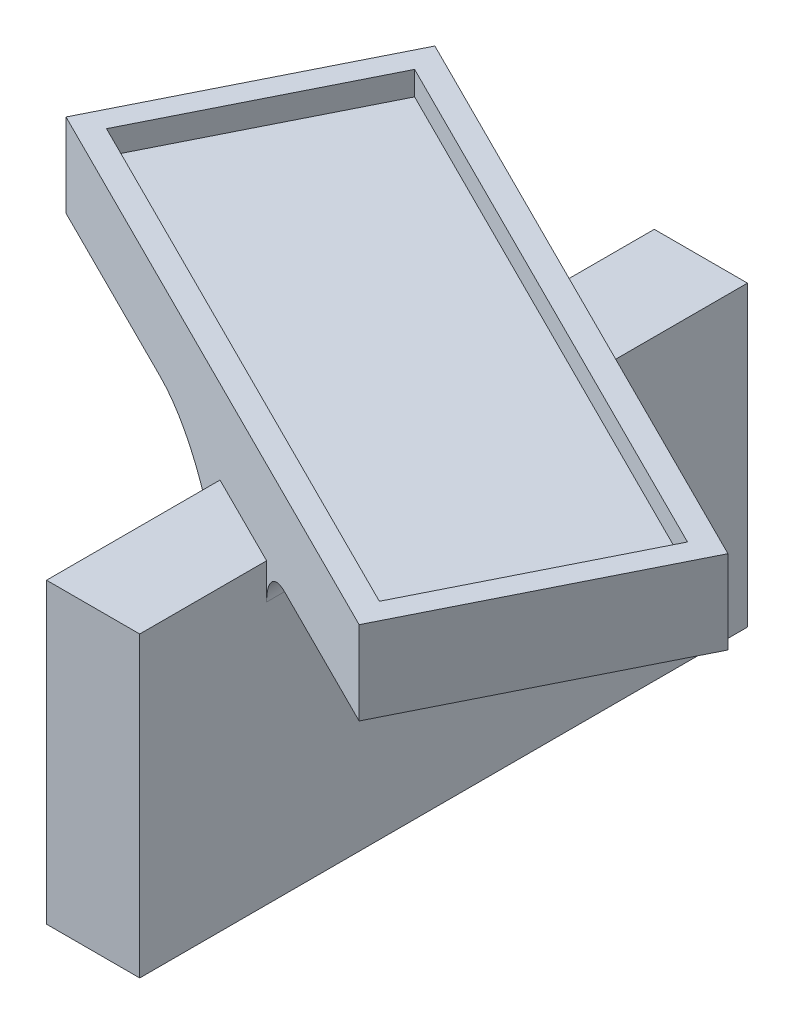
from build123d import *

# Parameters (mm, degrees)
SKETCH1_W           = 7.82
SKETCH1_H           = 51
BOSS_EXTRUDE1_DEPTH = 25
BOSS_EXTRUDE2_DEPTH = 5
BOSS_EXTRUDE3_DEPTH = 2
FILLET1_R           = 10
FILLET2_R           = 3
SKETCH4_W           = 3
SKETCH4_H           = 10
BOSS_EXTRUDE4_DEPTH = 2.5
CHAMFER1_SIZE       = 1


with BuildPart() as part:
    # Sketch1 → Boss-Extrude1 (new body)
    with BuildSketch(Plane(origin=(0, 0, 0), x_dir=(1, 0, 0), z_dir=(0, 1, 0))):
        Rectangle(SKETCH1_W, SKETCH1_H)
    extrude(amount=BOSS_EXTRUDE1_DEPTH)

    # Sketch2 → Boss-Extrude2 (add)
    with BuildSketch(Plane(origin=(0, 25, 0), x_dir=(1, 0, 0), z_dir=(0, 1, 0))):
        Polygon((-29.755356576, 1.98115624), (19.438138919, -22.615591532), (29.755356576, -1.98115624), (-19.438138919, 22.615591532), align=None)
    extrude(amount=BOSS_EXTRUDE2_DEPTH)

    # Sketch3 → Boss-Extrude3 (add)
    with BuildSketch(Plane(origin=(0, 30, 0), x_dir=(1, 0, 0), z_dir=(0, 1, 0))):
        Polygon((-29.755356576, 1.98115624), (19.438138919, -22.615591532), (29.755356576, -1.98115624), (-19.438138919, 22.615591532), align=None)
        Polygon((18.588433089, -20.066474038), (-27.206239081, 2.83086207), (-18.588433089, 20.066474038), (27.206239081, -2.83086207), align=None, mode=Mode.SUBTRACT)
    extrude(amount=BOSS_EXTRUDE3_DEPTH)

    # Fillet1
    fillet1_edges = [part.edges().sort_by_distance(p)[0] for p in [
        (-3.91, 25, -1.955000002),
    ]]
    fillet(fillet1_edges, radius=FILLET1_R)

    # Fillet2
    fillet2_edges = [part.edges().sort_by_distance(p)[0] for p in [
        (3.91, 25, 1.955000002),
    ]]
    fillet(fillet2_edges, radius=FILLET2_R)

    # Sketch4 → Boss-Extrude4 (add)
    with BuildSketch(Plane.ZY.offset(3.91)):
        Rectangle(SKETCH4_W, SKETCH4_H)
    extrude(amount=BOSS_EXTRUDE4_DEPTH)

    # Chamfer1
    chamfer1_edges = [part.edges().sort_by_distance(p)[0] for p in [
        (-3.91, 2.5, 1.5),
        (-3.91, 5, 0),
        (-3.91, 2.5, -1.5),
    ]]
    chamfer(chamfer1_edges, length=CHAMFER1_SIZE)


solid = part.part
